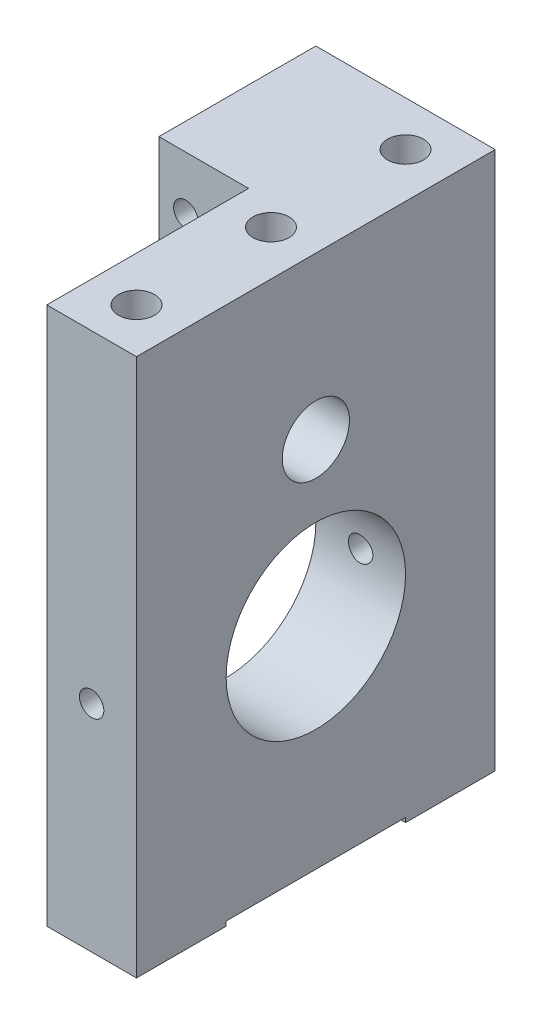
from build123d import *

# Parameters (mm, degrees)
SKETCH1_W                   = 50.8
SKETCH1_H                   = 76.2
BOSS_EXTRUDE1_DEPTH         = 6.35
F_1_4_20_TAPPED_HOLE1_D     = 5.1054
F_1_4_20_TAPPED_HOLE1_DEPTH = 19.05
F_1_4_20_TAPPED_HOLE1_TIP   = 1.533816902
CUT_EXTRUDE1_REACH          = 14.7
SKETCH5_W                   = 25.4
SKETCH5_H                   = 0.635
F_1_4_20_TAPPED_HOLE2_D     = 5.1054
F_1_4_20_TAPPED_HOLE2_DEPTH = 19.05
F_1_4_20_TAPPED_HOLE2_TIP   = 1.533816902
CUT_EXTRUDE2_REACH          = 14.7
SKETCH8_R                   = 12.7
SKETCH9_W                   = 22.225
SKETCH9_H                   = 19.05
BOSS_EXTRUDE2_DEPTH         = 12.7
F_8_32_TAPPED_HOLE1_D       = 3.4544
SKETCH12_R                  = 4.7625
CUT_EXTRUDE3_DEPTH          = 26.4
F_8_32_TAPPED_HOLE2_D       = 3.4544


with BuildPart() as part:
    # Sketch1 → Boss-Extrude1 (new body, symmetric)
    with BuildSketch(Plane(origin=(0, 0, 0), x_dir=(0, 0, -1), z_dir=(1, 0, 0))):
        Rectangle(SKETCH1_W, SKETCH1_H)
    extrude(amount=BOSS_EXTRUDE1_DEPTH, both=True)

    # 1/4-20 Tapped Hole1
    with Locations(Plane(origin=(0, -38.1, 0), x_dir=(-1, 0, 0), z_dir=(0, -1, 0))):
        with Locations((0, -19.05), (0, 19.05)):
            Hole(F_1_4_20_TAPPED_HOLE1_D / 2, depth=F_1_4_20_TAPPED_HOLE1_DEPTH)
            with Locations((0, 0, -(F_1_4_20_TAPPED_HOLE1_DEPTH + F_1_4_20_TAPPED_HOLE1_TIP / 2))):  # 118° drill point
                Cone(0, F_1_4_20_TAPPED_HOLE1_D / 2, F_1_4_20_TAPPED_HOLE1_TIP, mode=Mode.SUBTRACT)

    # Sketch5 → Cut-Extrude1 (cut, up to next)
    with BuildSketch(Plane(origin=(6.35, 0, 0), x_dir=(0, 0, -1), z_dir=(1, 0, 0)), mode=Mode.PRIVATE) as cut_extrude1_sk1:
        with Locations((0, -37.7825)):
            Rectangle(SKETCH5_W, SKETCH5_H)
    cut_extrude1_tool1 = extrude(cut_extrude1_sk1.sketch, amount=-CUT_EXTRUDE1_REACH, mode=Mode.PRIVATE) & part.part
    add(cut_extrude1_tool1.solids().sort_by_distance((6.35, -37.7825, 0))[0], mode=Mode.SUBTRACT)

    # 1/4-20 Tapped Hole2
    with Locations(Plane(origin=(0, 38.1, 0), x_dir=(1, 0, 0), z_dir=(0, 1, 0))):
        with Locations((0, 19.05), (0, 0), (0, -19.05)):
            Hole(F_1_4_20_TAPPED_HOLE2_D / 2, depth=F_1_4_20_TAPPED_HOLE2_DEPTH)
            with Locations((0, 0, -(F_1_4_20_TAPPED_HOLE2_DEPTH + F_1_4_20_TAPPED_HOLE2_TIP / 2))):  # 118° drill point
                Cone(0, F_1_4_20_TAPPED_HOLE2_D / 2, F_1_4_20_TAPPED_HOLE2_TIP, mode=Mode.SUBTRACT)

    # Sketch8 → Cut-Extrude2 (cut, up to next)
    with BuildSketch(Plane(origin=(6.35, 0, 0), x_dir=(0, 0, -1), z_dir=(1, 0, 0)), mode=Mode.PRIVATE) as cut_extrude2_sk1:
        with Locations((0, -7.62)):
            Circle(SKETCH8_R)
    cut_extrude2_tool1 = extrude(cut_extrude2_sk1.sketch, amount=-CUT_EXTRUDE2_REACH, mode=Mode.PRIVATE) & part.part
    add(cut_extrude2_tool1.solids().sort_by_distance((6.35, -7.62, 0))[0], mode=Mode.SUBTRACT)

    # Sketch9 → Boss-Extrude2 (add)
    with BuildSketch(Plane.ZY.offset(6.35)):
        with Locations((-14.2875, 28.575)):
            Rectangle(SKETCH9_W, SKETCH9_H)
    extrude(amount=BOSS_EXTRUDE2_DEPTH)

    # #8-32 Tapped Hole1 (through all)
    with Locations(Plane.XY.offset(-3.175)):
        with Locations((-15.24, 30.48)):
            Hole(F_8_32_TAPPED_HOLE1_D / 2)

    # Sketch12 → Cut-Extrude3 (cut, through all)
    with BuildSketch(Plane(origin=(6.35, 0, 0), x_dir=(0, 0, -1), z_dir=(1, 0, 0))):
        with Locations((0, 15.24)):
            Circle(SKETCH12_R)
    extrude(amount=-CUT_EXTRUDE3_DEPTH, mode=Mode.SUBTRACT)

    # #8-32 Tapped Hole2 (through all)
    with Locations(Plane.XY.offset(25.4)):
        with Locations((0, -7.62)):
            Hole(F_8_32_TAPPED_HOLE2_D / 2)


solid = part.part
